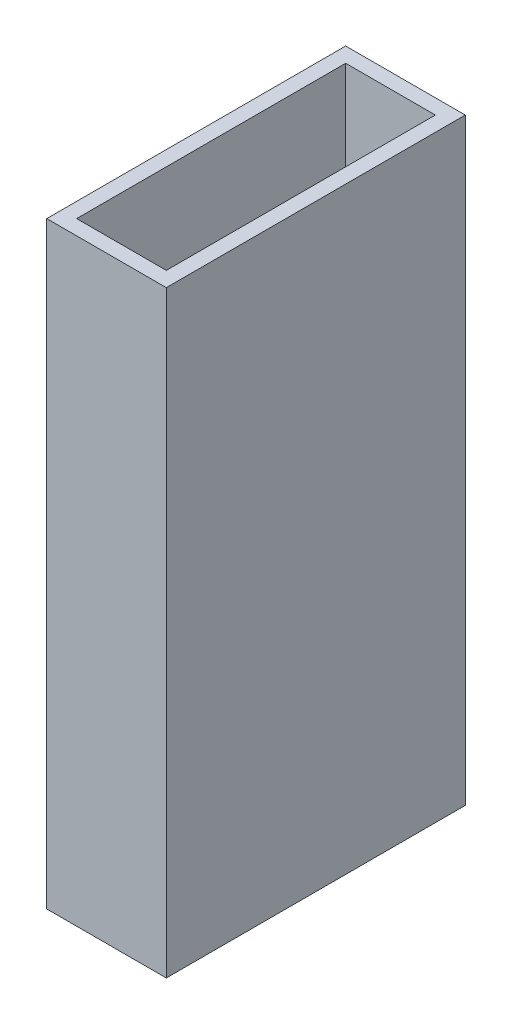
from build123d import *

# Parameters (mm, degrees)
SKETCH1_W           = 40
SKETCH1_H           = 100
BOSS_EXTRUDE1_DEPTH = 200
SHELL2_T            = -5


with BuildPart() as part:
    # Sketch1 → Boss-Extrude1 (new body)
    with BuildSketch(Plane(origin=(0, 0, 0), x_dir=(1, 0, 0), z_dir=(0, 1, 0))):
        Rectangle(SKETCH1_W, SKETCH1_H)
    extrude(amount=BOSS_EXTRUDE1_DEPTH)

    # Shell2
    shell2_openings = [part.faces().sort_by_distance(p)[0] for p in [
        (0, 200, 0),
    ]]
    offset(amount=SHELL2_T, openings=shell2_openings, kind=Kind.INTERSECTION)


solid = part.part
